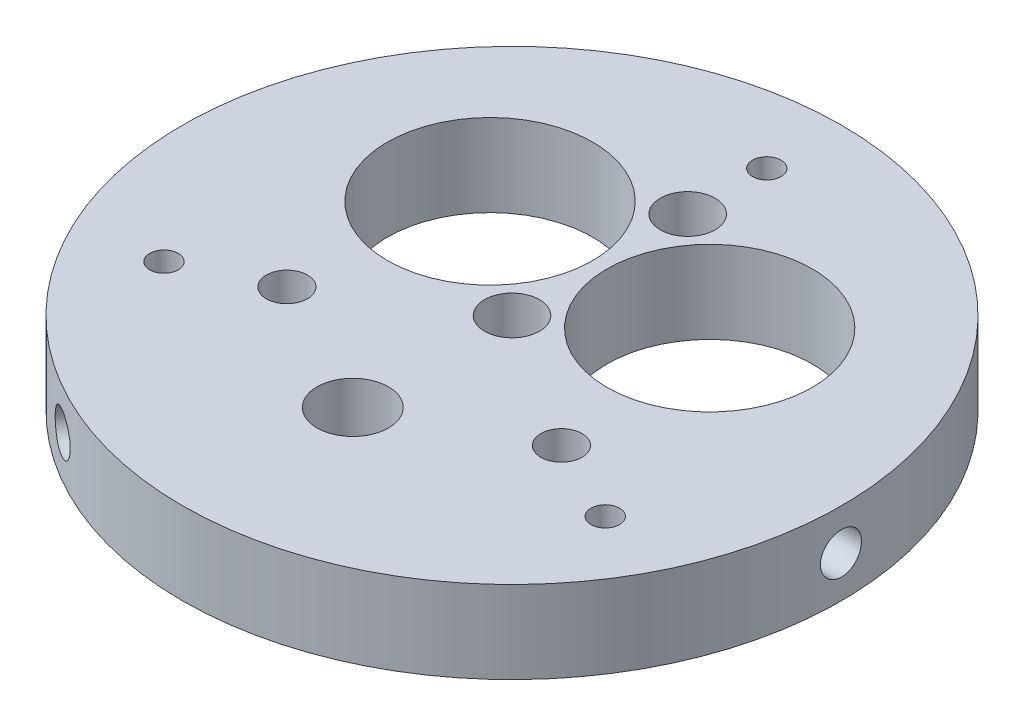
from build123d import *

# Parameters (mm, degrees)
SKETCH1_R               = 38.1127
BOSS_EXTRUDE1_DEPTH     = 9.525
SKETCH2_R               = 1.651
SKETCH2_R_2             = 4.1275
SKETCH2_R_3             = 11.8745
SKETCH2_R_4             = 3.175
CUT_EXTRUDE1_DEPTH      = 55.734645587
SKETCH4_R               = 2.3749
CUT_EXTRUDE2_DEPTH      = 6.35
CIRPATTERN1_COUNT       = 3
CUT_EXTRUDE3_DEPTH      = 55.734645744
CUT_EXTRUDE3_DEPTH_BACK = 55.734645744
SKETCH5_R               = 2.38125


with BuildPart() as part:
    # Sketch1 → Boss-Extrude1 (new body)
    with BuildSketch(Plane(origin=(0, 0, 0), x_dir=(1, 0, 0), z_dir=(0, 1, 0))):
        Circle(SKETCH1_R)
    extrude(amount=BOSS_EXTRUDE1_DEPTH)

    # Sketch2 → Cut-Extrude1 (cut, through all)
    with BuildSketch(Plane(origin=(0, 9.525, 0), x_dir=(1, 0, 0), z_dir=(0, 1, 0))):
        with Locations((0, 29.464)):
            Circle(SKETCH2_R)
        with Locations((25.516572497, -14.732)):
            Circle(SKETCH2_R)
        with Locations((-25.516572497, -14.732)):
            Circle(SKETCH2_R)
        with Locations((0, -18.415)):
            Circle(SKETCH2_R_2)
        with Locations((-12.7, 10.16)):
            Circle(SKETCH2_R_3)
        with Locations((12.7, 10.16)):
            Circle(SKETCH2_R_3)
        with Locations((0, 20.32)):
            Circle(SKETCH2_R_4)
        Circle(SKETCH2_R_4)
    extrude(amount=-CUT_EXTRUDE1_DEPTH, mode=Mode.SUBTRACT)

    # Sketch4 → Cut-Extrude2 (cut)
    with BuildSketch(Plane(origin=(-19.05635, 0, -33.006566407), x_dir=(0, -1, 0), z_dir=(-0.499999999999998, 0, -0.8660254037844398))):
        with Locations((-4.7625, 0)):
            Circle(SKETCH4_R)
    cut_extrude2 = extrude(amount=-CUT_EXTRUDE2_DEPTH, mode=Mode.SUBTRACT)

    # CirPattern1: Cut-Extrude2 ×3 about axis
    cirpattern1_axis = Axis((0, 10.00125, 0), (0, -1, 0))
    for i in range(1, CIRPATTERN1_COUNT):
        add(cut_extrude2.rotate(cirpattern1_axis, i * 360 / CIRPATTERN1_COUNT), mode=Mode.SUBTRACT)

    # Sketch5 → Cut-Extrude3 (cut, two sides: drawn at the far end of the back side and taken through both)
    with BuildSketch(Plane(origin=(0, 9.525, 0), x_dir=(1, 0, 0), z_dir=(0, 1, 0)).offset(-CUT_EXTRUDE3_DEPTH_BACK)):
        with Locations((-15.875, -10.16)):
            Circle(SKETCH5_R)
        with Locations((15.875, -10.16)):
            Circle(SKETCH5_R)
    extrude(amount=CUT_EXTRUDE3_DEPTH + CUT_EXTRUDE3_DEPTH_BACK, mode=Mode.SUBTRACT)


solid = part.part
